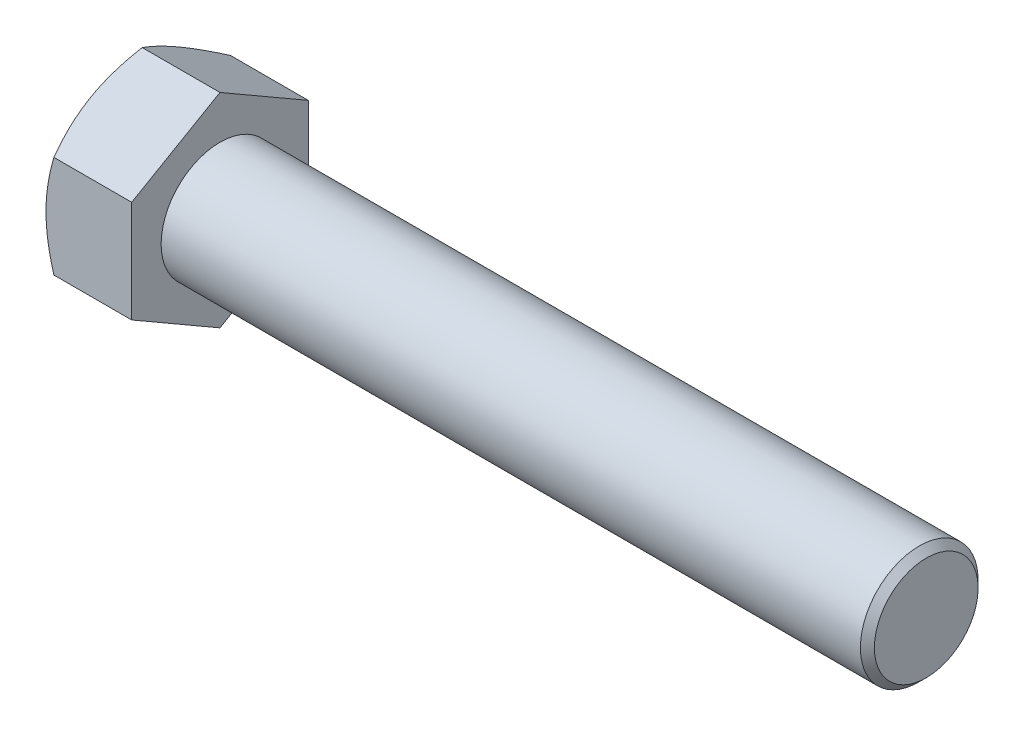
from build123d import *

# Parameters (mm, degrees)
BASEHEAD_DEPTH = 9.2456


with BuildPart() as part:
    # Sketch1 → BaseHead (new body)
    with BuildSketch(Plane(origin=(0, 0, 0), x_dir=(0, 0, -1), z_dir=(1, 0, 0))):
        Polygon((9.525, 5.499261314), (9.525, -5.499261314), (0, -10.998522628), (-9.525, -5.499261314), (-9.525, 5.499261314), (0, 10.998522628), align=None)
    extrude(amount=BASEHEAD_DEPTH)

    # BodySke → BaseBody (revolve)
    with BuildSketch(Plane.XY):
        Polygon((0, 0), (85.4456, 0), (85.4456, 5.59435), (84.68995, 6.35), (0, 6.35), align=None)
    revolve(axis=Axis((0, 0, 0), (1, 0, 0)))

    # Sketch3 → HeadChamfer (revolve, cut)
    with BuildSketch(Plane.XY):
        Polygon((0, 9.525), (4.516912895, 17.348522628), (4.516912895, 23.698522628), (-12.7, 23.698522628), (-12.7, 9.525), align=None)
    revolve(axis=Axis((0, 0, 0), (1, 0, 0)), mode=Mode.SUBTRACT)


solid = part.part
